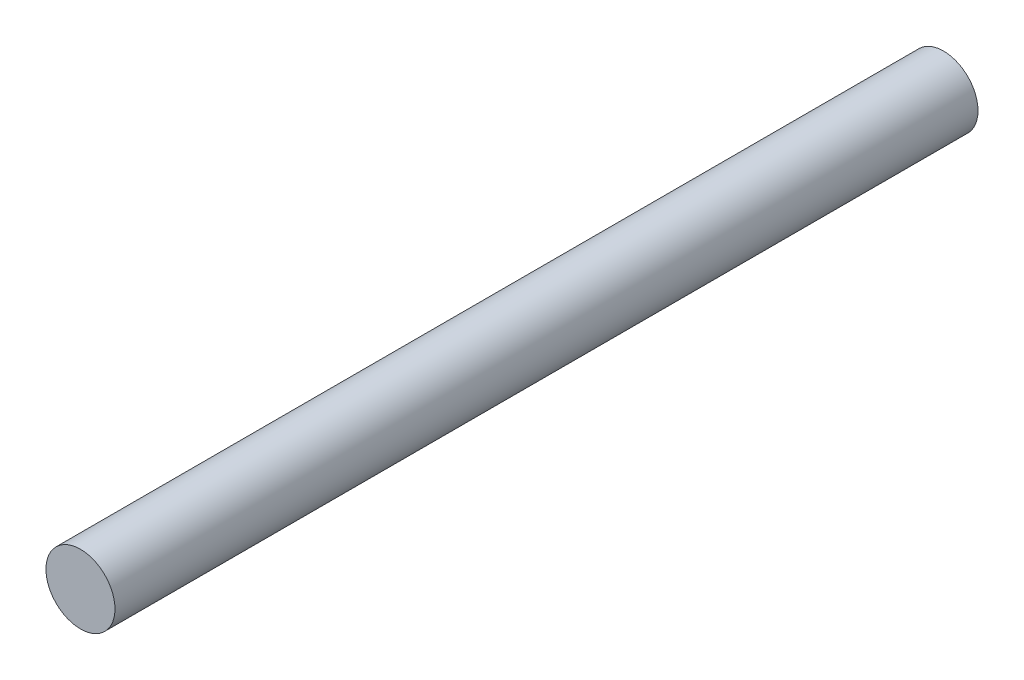
from build123d import *

# Parameters (mm, degrees)
SKETCH1_R           = 4
BOSS_EXTRUDE1_DEPTH = 100


with BuildPart() as part:
    # Sketch1 → Boss-Extrude1 (new body)
    with BuildSketch(Plane.XY):
        Circle(SKETCH1_R)
    extrude(amount=BOSS_EXTRUDE1_DEPTH)


solid = part.part
